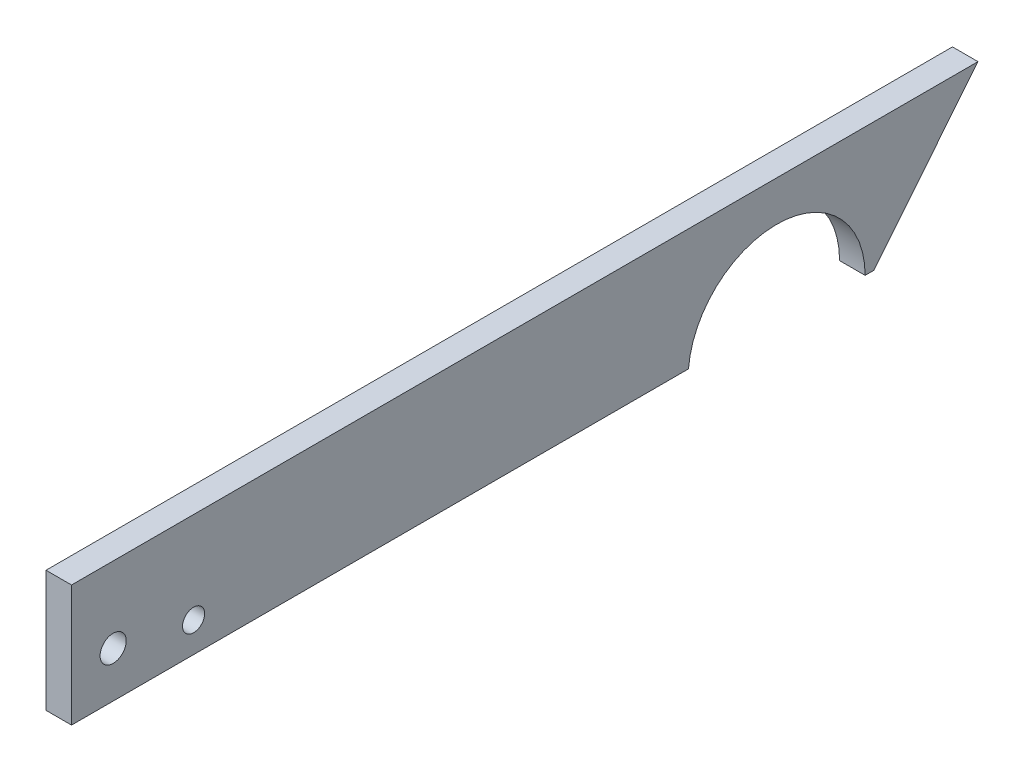
from build123d import *

# Parameters (mm, degrees)
SKETCH1_R           = 3.25
SKETCH1_R_2         = 2.75
BOSS_EXTRUDE1_DEPTH = 6.35


with BuildPart() as part:
    # Sketch1 → Boss-Extrude1 (new body)
    with BuildSketch(Plane(origin=(0, 0, 0), x_dir=(0, 0, -1), z_dir=(1, 0, 0))):
        with BuildLine():
            Line((-175.353584658, 32), (50.071343536, 32))
            Line((50.071343536, 32), (24.152715011, 0))
            Line((24.152715011, 0), (22, 0))
            ThreePointArc((22, 0), (0.91041892, 21.981154141), (-21.924648854, 1.819278055))
            Line((-21.924648854, 1.819278055), (-175.353584658, 1.819278055))
            Line((-175.353584658, 1.819278055), (-175.353584658, 32))
        make_face()
        with Locations((-165, 13.1796749)):
            Circle(SKETCH1_R, mode=Mode.SUBTRACT)
        with Locations((-145, 9.287146811)):
            Circle(SKETCH1_R_2, mode=Mode.SUBTRACT)
    extrude(amount=BOSS_EXTRUDE1_DEPTH)


solid = part.part
